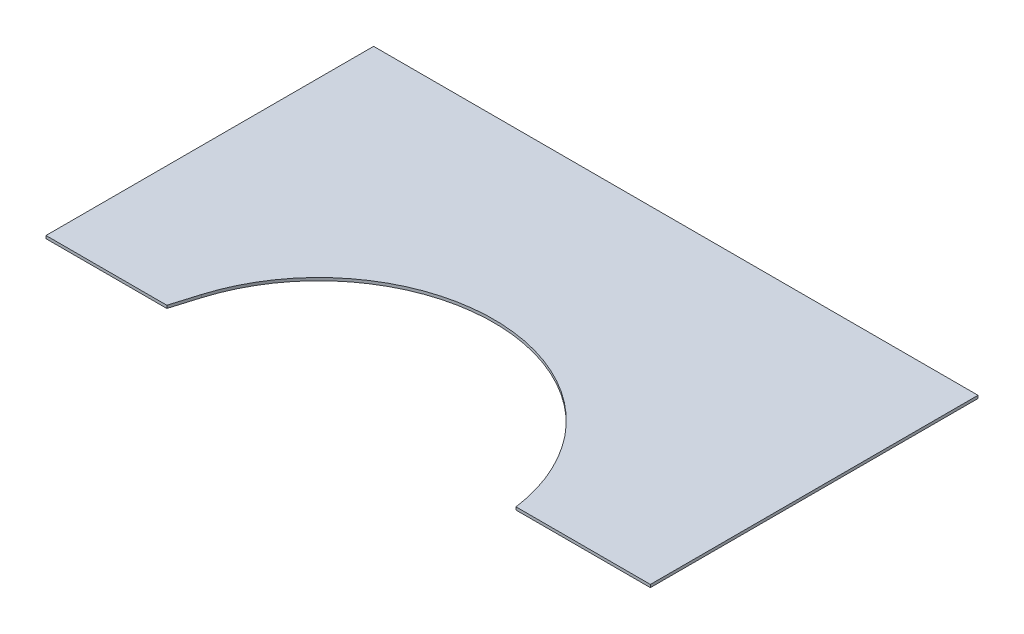
from build123d import *

# Parameters (mm, degrees)
SKETCH1_W           = 679.45
SKETCH1_H           = 368.3
BOSS_EXTRUDE1_DEPTH = 3.175
CUT_EXTRUDE1_DEPTH  = 4.175


with BuildPart() as part:
    # Sketch1 → Boss-Extrude1 (new body)
    with BuildSketch(Plane(origin=(0, 0, 0), x_dir=(1, 0, 0), z_dir=(0, 1, 0))):
        with Locations((339.725, 184.15)):
            Rectangle(SKETCH1_W, SKETCH1_H)
    extrude(amount=BOSS_EXTRUDE1_DEPTH)

    # Sketch2 → Cut-Extrude1 (cut, through all)
    with BuildSketch(Plane(origin=(0, 3.175, 0), x_dir=(1, 0, 0), z_dir=(0, 1, 0))):
        with BuildLine():
            Line((135.832993334, 0), (144.943397545, 30.143073778))
            ThreePointArc((144.943397545, 30.143073778), (213.497085422, 129.330172419), (327.025, 169.939300333))
            ThreePointArc((327.025, 169.939300333), (472.568969877, 112.385716223), (530.122553987, -33.158253654))
            ThreePointArc((530.122553987, -33.158253654), (520.134888885, -89.022933623), (494.625079918, -139.71677515))
            add(Edge.make_bspline(
                [(494.625079918, -139.71677515), (493.45726691, -141.384584969), (490.895198527, -144.528294755), (484.77915912, -150.233837552), (475.335730084, -156.231610738), (461.521693133, -161.444305371), (379.648366594, -177.46097032), (267.722400389, -112.187788034), (488.667649379, 0)],
                knots=[0, 0, 0, 0, 0.027722316, 0.055444633, 0.110889265, 0.166333898, 0.22177853, 0.984715491, 0.984715491, 0.984715491, 0.984715491], degree=3))
            Line((488.667649379, 0), (135.832993334, 0))
        make_face()
    extrude(amount=-CUT_EXTRUDE1_DEPTH, mode=Mode.SUBTRACT)


solid = part.part
